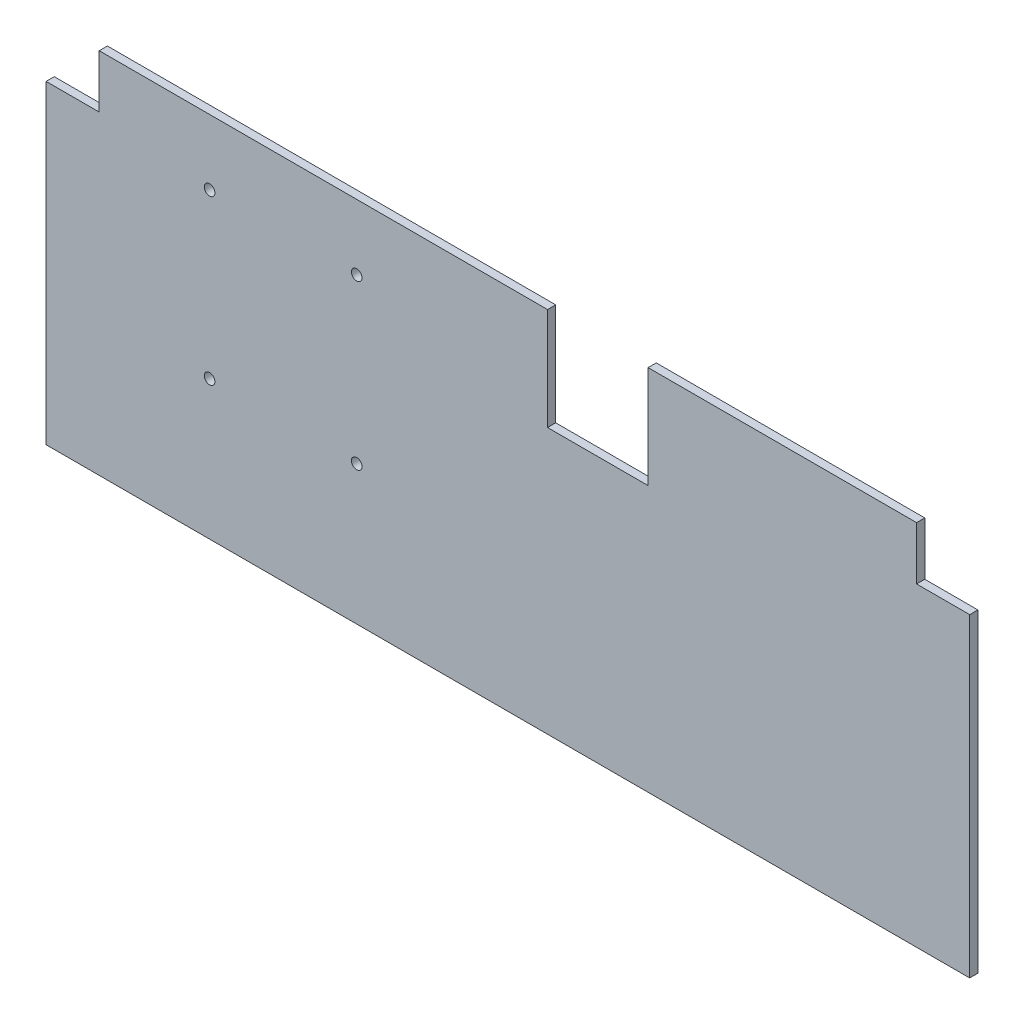
from build123d import *

# Parameters (mm, degrees)
SKETCH1_W                  = 1130
SKETCH1_H                  = 450
BOSS_EXTRUDE1_DEPTH        = 10
SKETCH2_W                  = 65
SKETCH2_H                  = 65
CUT_EXTRUDE1_DEPTH         = 11
SKETCH3_W                  = 123
SKETCH3_H                  = 125
CUT_EXTRUDE2_DEPTH         = 11
F_13_0_13_DIAMETER_HOLE1_D = 13


with BuildPart() as part:
    # Sketch1 → Boss-Extrude1 (new body)
    with BuildSketch(Plane.XY):
        with Locations((0, -25)):
            Rectangle(SKETCH1_W, SKETCH1_H)
    extrude(amount=BOSS_EXTRUDE1_DEPTH)

    # Sketch2 → Cut-Extrude1 (cut, through all)
    with BuildSketch(Plane.XY.offset(10)):
        with Locations((-532.5, 167.5)):
            Rectangle(SKETCH2_W, SKETCH2_H)
    cut_extrude1 = extrude(amount=-CUT_EXTRUDE1_DEPTH, mode=Mode.SUBTRACT)

    # Mirror1: Cut-Extrude1 across plane
    add(cut_extrude1.mirror(Plane(origin=(0, 0, 0), x_dir=(0, 0, 1), z_dir=(1, 0, 0))), mode=Mode.SUBTRACT)

    # Sketch3 → Cut-Extrude2 (cut, through all)
    with BuildSketch(Plane.XY.offset(10)):
        with Locations((110, 137.5)):
            Rectangle(SKETCH3_W, SKETCH3_H)
    extrude(amount=-CUT_EXTRUDE2_DEPTH, mode=Mode.SUBTRACT)

    # Ø13.0 (13) Diameter Hole1 (through all)
    with Locations(Plane.XY.offset(10)):
        with Locations((-365, 120), (-185, 120), (-185, -80), (-365, -80)):
            Hole(F_13_0_13_DIAMETER_HOLE1_D / 2)


solid = part.part
